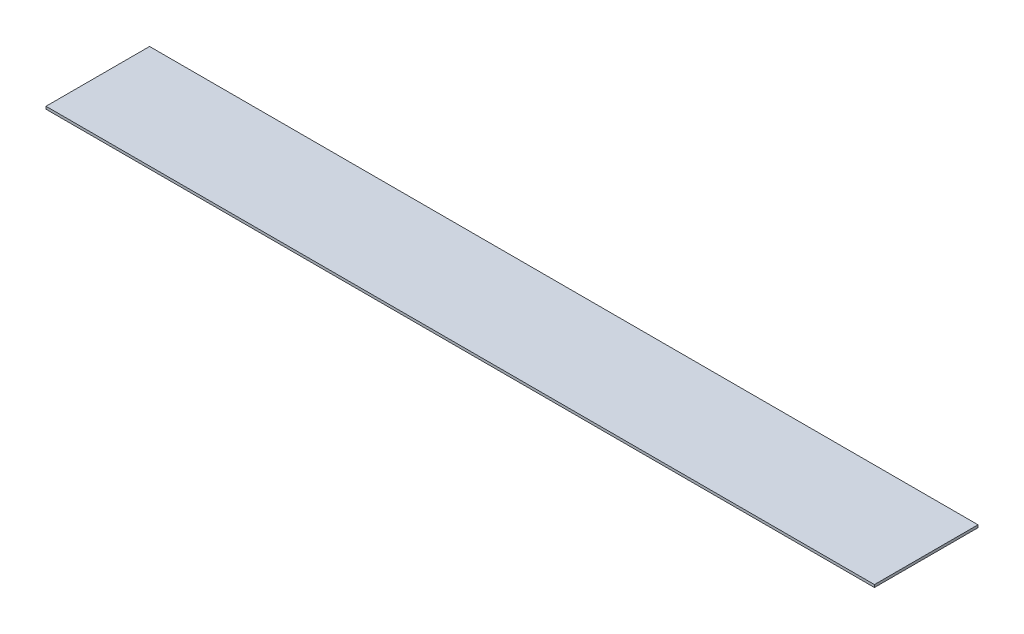
from build123d import *

# Parameters (mm, degrees)
SKETCH1_W           = 406.4
SKETCH1_H           = 50.8
BOSS_EXTRUDE1_DEPTH = 1.27


with BuildPart() as part:
    # Sketch1 → Boss-Extrude1 (new body)
    with BuildSketch(Plane(origin=(0, 0, 0), x_dir=(1, 0, 0), z_dir=(0, 1, 0))):
        with Locations((203.2, 25.4)):
            Rectangle(SKETCH1_W, SKETCH1_H)
    extrude(amount=BOSS_EXTRUDE1_DEPTH)


solid = part.part
